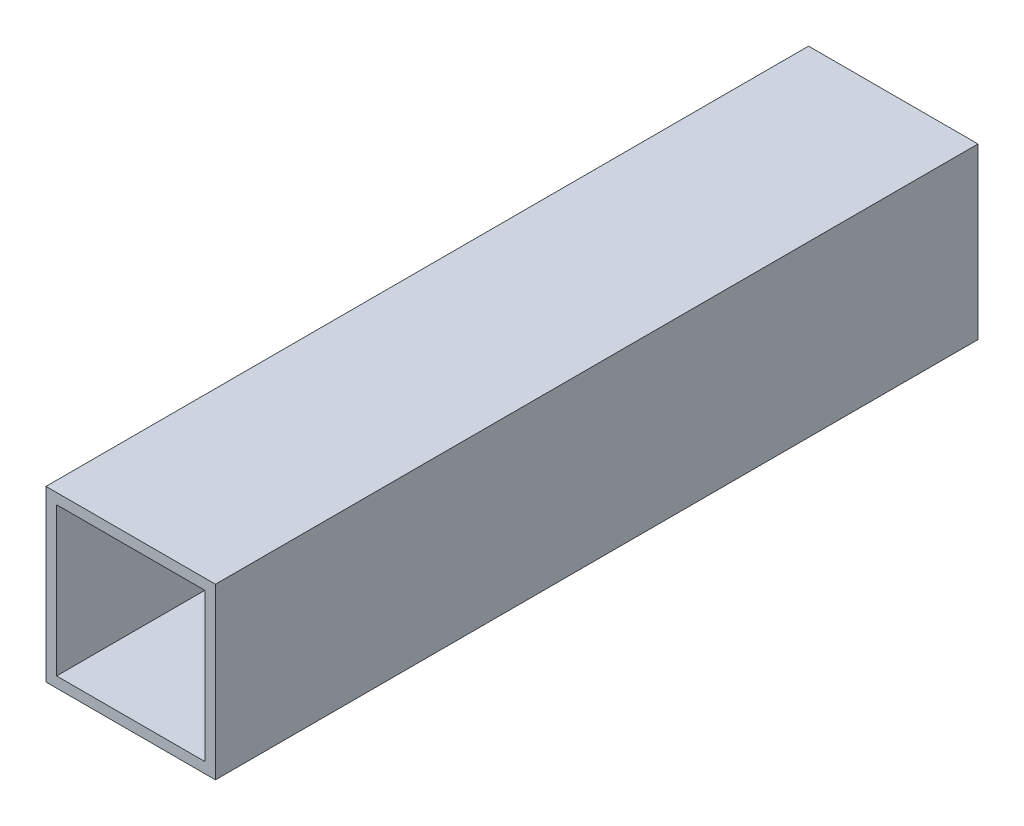
from build123d import *

# Parameters (mm, degrees)
SKETCH1_W           = 50.8
SKETCH1_H           = 50.8
SKETCH1_W_2         = 44.45
SKETCH1_H_2         = 44.45
BOSS_EXTRUDE1_DEPTH = 228.6


with BuildPart() as part:
    # Sketch1 → Boss-Extrude1 (new body)
    with BuildSketch(Plane.XY):
        with Locations((25.4, 25.4)):
            Rectangle(SKETCH1_W, SKETCH1_H)
        with Locations((25.4, 25.4)):
            Rectangle(SKETCH1_W_2, SKETCH1_H_2, mode=Mode.SUBTRACT)
    extrude(amount=BOSS_EXTRUDE1_DEPTH)


solid = part.part
